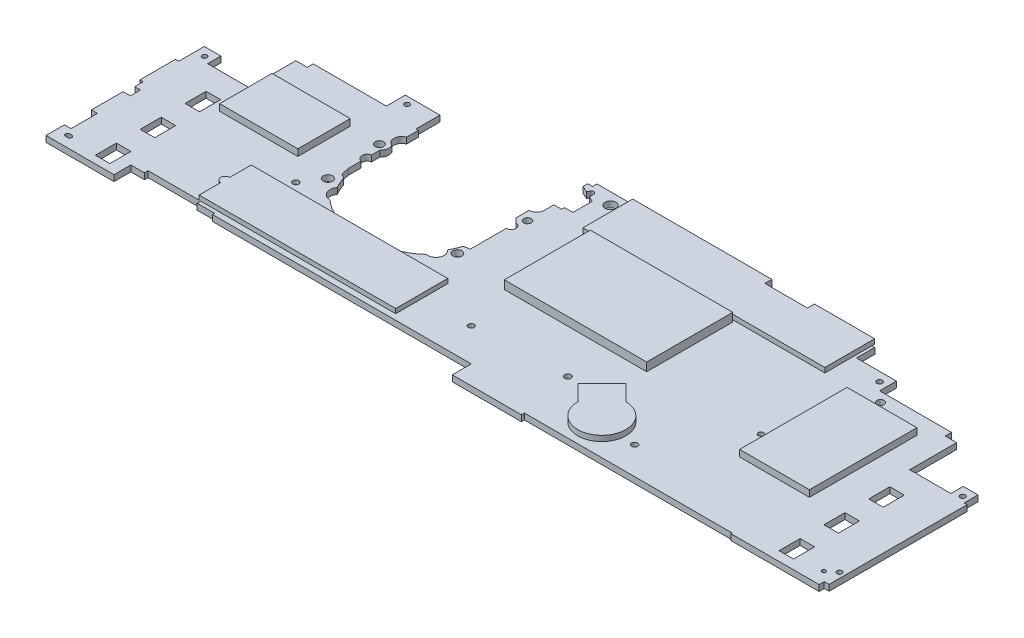
from build123d import *

# Parameters (mm, degrees)
BOSS_EXTRUDE1_DEPTH     = 2.54
SKETCH3_W               = 6.096
SKETCH3_H               = 8.89
SKETCH3_H_2             = 7.366
SKETCH3_R               = 1.016
SKETCH3_R_2             = 1.0795
SKETCH3_R_3             = 1.778
SKETCH3_R_4             = 1.9685
SKETCH3_R_5             = 1.27
SKETCH3_R_6             = 1.905
SKETCH3_R_7             = 2.286
SKETCH3_R_8             = 1.5875
SKETCH3_R_9             = 1.2065
SKETCH3_R_10            = 1.3335
SKETCH3_R_11            = 1.143
SKETCH3_R_12            = 1.524
SKETCH3_R_13            = 0.9525
SKETCH3_H_3             = 7.62
SKETCH3_R_14            = 0.8255
SKETCH3_H_4             = 1.27
SKETCH3_H_5             = 1.524
CUT_EXTRUDE1_DEPTH      = 201.628810234
CUT_EXTRUDE1_DEPTH_BACK = 201.628810234
SKETCH4_R               = 1.905
SKETCH4_W               = 82.931
SKETCH4_H               = 21.971
BOSS_EXTRUDE2_DEPTH     = 1.905
BOSS_EXTRUDE3_DEPTH     = 2
SKETCH6_W               = 60.071
SKETCH6_H               = 36.322
BOSS_EXTRUDE4_DEPTH     = 3.556
SKETCH7_W               = 29.464
SKETCH7_H               = 45.339
BOSS_EXTRUDE5_DEPTH     = 2.794
SKETCH8_W               = 33.02
SKETCH8_H               = 22.1
BOSS_EXTRUDE6_DEPTH     = 2.794
BOSS_EXTRUDE7_DEPTH     = 2.286


with BuildPart() as part:
    # Sketch1 → Boss-Extrude1 (new body)
    with BuildSketch(Plane(origin=(0, 0, 0), x_dir=(1, 0, 0), z_dir=(0, 1, 0))):
        with BuildLine():
            Line((0, 8.001), (0, 0))
            Line((0, 0), (29.21, 0))
            Line((29.21, 0), (29.21, 1.27))
            Line((29.21, 1.27), (116.84, 1.27))
            Line((116.84, 1.27), (116.84, 0.762))
            Line((116.84, 0.762), (154.051, 0.762))
            Line((154.051, 0.762), (154.051, 2.921))
            Line((154.051, 2.921), (156.083, 2.921))
            Line((156.083, 2.921), (156.083, 61.214))
            Line((156.083, 61.214), (154.813, 61.214))
            Line((154.813, 61.214), (154.813, 67.056))
            Line((154.813, 67.056), (148.59, 67.056))
            Line((148.59, 67.056), (148.59, 61.849))
            Line((148.59, 61.849), (131.191, 61.849))
            Line((131.191, 61.849), (131.191, 81.661))
            Line((131.191, 81.661), (126.365, 81.661))
            Line((126.365, 81.661), (126.365, 84.328))
            Line((126.365, 84.328), (96.012, 84.328))
            Line((96.012, 84.328), (96.012, 91.44))
            Line((96.012, 91.44), (79.121, 91.44))
            Line((79.121, 91.44), (79.121, 99.187))
            Line((79.121, 99.187), (42.799, 99.187))
            Line((42.799, 99.187), (42.799, 98.044))
            Line((42.799, 98.044), (35.687, 98.044))
            Line((35.687, 98.044), (35.687, 99.187))
            Line((35.687, 99.187), (34.544, 99.187))
            Line((34.544, 99.187), (34.544, 100.33))
            Line((34.544, 100.33), (-39.243, 100.33))
            Line((-39.243, 100.33), (-39.255297848, 98.431967979))
            Line((-39.255297848, 98.431967979), (-41.287297848, 98.431967979))
            Line((-41.287297848, 98.431967979), (-41.287297848, 96.526967979))
            Line((-41.287297848, 96.526967979), (-38.656255201, 95.245681884))
            ThreePointArc((-38.656255201, 95.245681884), (-38.631310271, 95.294399354), (-38.604432984, 95.342077996))
            Line((-38.604432984, 95.342077996), (-38.04630951, 96.380260766))
            ThreePointArc((-38.04630951, 96.380260766), (-36.937365197, 96.869438836), (-36.192249582, 95.913480995))
            Line((-36.192249582, 95.913480995), (-36.108358632, 94.99611778))
            ThreePointArc((-36.108358632, 94.99611778), (-36.074534662, 94.823441321), (-36.063197248, 94.647848942))
            ThreePointArc((-36.063197248, 94.647848942), (-36.064170573, 94.596301921), (-36.06708916, 94.544828388))
            ThreePointArc((-36.06708916, 94.544828388), (-36.110630044, 94.291080338), (-36.201028424, 94.050016001))
            Line((-36.201028424, 94.050016001), (-33.909, 92.933825752))
            Line((-33.909, 92.933825752), (-33.909, 84.837778338))
            Line((-33.909, 84.837778338), (-37.42811281, 84.837778338))
            Line((-37.42811281, 84.837778338), (-37.42811281, 83.592829399))
            Line((-37.42811281, 83.592829399), (-40.714778008, 83.592829399))
            Line((-40.714778008, 83.592829399), (-40.714778008, 79.537332166))
            ThreePointArc((-40.714778008, 79.537332166), (-41.65506253, 77.267284521), (-43.925110174, 76.327))
            Line((-43.925110174, 76.327), (-43.925110174, 70.782176931))
            Line((-43.925110174, 70.782176931), (-42.14209679, 69.03393907))
            ThreePointArc((-42.14209679, 69.03393907), (-40.073627255, 66.965469535), (-42.14209679, 64.897))
            Line((-42.14209679, 64.897), (-42.14209679, 49.657))
            Line((-42.14209679, 49.657), (-44.657164641, 49.38207208))
            ThreePointArc((-44.657164641, 49.38207208), (-45.543124553, 46.96731208), (-46.71163595, 44.675899429))
            ThreePointArc((-46.71163595, 44.675899429), (-45.665282525, 40.5161147), (-49.482783297, 38.560263904))
            ThreePointArc((-49.482783297, 38.560263904), (-53.685297352, 35.471118381), (-58.472630046, 33.401))
            Line((-58.472630046, 33.401), (-81.840630046, 33.401))
            ThreePointArc((-81.840630046, 33.401), (-86.00575496, 35.359647644), (-89.703732123, 38.1))
            ThreePointArc((-89.703732123, 38.1), (-93.118126886, 40.221112124), (-92.731191221, 44.222048143))
            ThreePointArc((-92.731191221, 44.222048143), (-93.960639772, 46.584635963), (-94.890455929, 49.080393736))
            Line((-94.890455929, 49.080393736), (-96.52, 49.94461297))
            Line((-96.52, 49.94461297), (-97.385045708, 53.369572597))
            Line((-97.385045708, 53.369572597), (-97.385045708, 58.928))
            ThreePointArc((-97.385045708, 58.928), (-99.236932605, 61.135672369), (-97.385045708, 63.343344739))
            Line((-97.385045708, 63.343344739), (-97.385045708, 66.898875353))
            ThreePointArc((-97.385045708, 66.898875353), (-96.253026819, 68.876310747), (-96.649985306, 71.12))
            ThreePointArc((-96.649985306, 71.12), (-98.747141094, 74.213443411), (-96.52, 77.214659345))
            Line((-96.52, 77.214659345), (-96.52, 82.169))
            Line((-96.52, 82.169), (-97.536, 82.169))
            Line((-97.536, 82.169), (-97.536, 92.329))
            Line((-97.536, 92.329), (-112.141, 92.329))
            Line((-112.141, 92.329), (-112.141, 84.328))
            Line((-112.141, 84.328), (-143.002, 84.328))
            Line((-143.002, 84.328), (-143.002, 81.788))
            Line((-143.002, 81.788), (-147.828, 81.788))
            Line((-147.828, 81.788), (-147.828, 62.103))
            Line((-147.828, 62.103), (-165.354, 62.103))
            Line((-165.354, 62.103), (-165.354, 67.691))
            Line((-165.354, 67.691), (-172.339, 67.691))
            Line((-172.339, 67.691), (-172.339, 56.896))
            Line((-172.339, 56.896), (-173.736, 56.896))
            Line((-173.736, 56.896), (-173.736, 41.91))
            Line((-173.736, 41.91), (-172.339, 41.91))
            Line((-172.339, 41.91), (-172.339, 38.354))
            Line((-172.339, 38.354), (-169.926, 38.354))
            Line((-169.926, 38.354), (-169.926, 34.036))
            Line((-169.926, 34.036), (-172.974, 34.036))
            Line((-172.974, 34.036), (-172.974, 20.701))
            Line((-172.974, 20.701), (-170.434, 20.701))
            Line((-170.434, 20.701), (-170.434, 9.525))
            Line((-170.434, 9.525), (-173.228, 9.525))
            Line((-173.228, 9.525), (-173.228, 1.778))
            Line((-173.228, 1.778), (-144.526, 1.778))
            Line((-144.526, 1.778), (-144.526, 8.89))
            Line((-144.526, 8.89), (-138.811, 8.89))
            Line((-138.811, 8.89), (-138.811, 10.414))
            Line((-138.811, 10.414), (-116.586, 10.414))
            Line((-116.586, 10.414), (-116.586, 8.89))
            Line((-116.586, 8.89), (-109.22, 8.89))
            Line((-109.22, 8.89), (-109.22, 8.001))
            Line((-109.22, 8.001), (0, 8.001))
        make_face()
    extrude(amount=BOSS_EXTRUDE1_DEPTH)

    # Sketch3 → Cut-Extrude1 (cut, two sides)
    with BuildSketch(Plane(origin=(0, 1.27, 0), x_dir=(1, 0, 0), z_dir=(0, 1, 0))) as cut_extrude1_sk:
        with BuildLine():
            Line((-168.783, 5.588), (-167.894, 5.588))
            ThreePointArc((-167.894, 5.588), (-167.005, 6.477), (-167.894, 7.366))
            Line((-167.894, 7.366), (-168.783, 7.366))
            ThreePointArc((-168.783, 7.366), (-169.672, 6.477), (-168.783, 5.588))
        make_face()
        with Locations((-152.527, 9.398)):
            Rectangle(SKETCH3_W, SKETCH3_H)
        with Locations((-152.527, 28.321)):
            Rectangle(SKETCH3_W, SKETCH3_H)
        with Locations((-152.527, 46.482)):
            Rectangle(SKETCH3_W, SKETCH3_H_2)
        with Locations(Location((-168.656, 64.135, 0), (0, 0, 270))):
            Circle(SKETCH3_R)
        with Locations(Location((-108.3945, 89.3445, 0), (0, 0, 270))):
            Circle(SKETCH3_R_2)
        with Locations(Location((-99.695, 68.961, 0), (0, 0, 270))):
            Circle(SKETCH3_R_3)
        with Locations(Location((-97.9805, 45.5295, 0), (0, 0, 270))):
            Circle(SKETCH3_R_4)
        with Locations(Location((-103.378, 37.338, 0), (0, 0, 270))):
            Circle(SKETCH3_R_5)
        with Locations(Location((-43.307, 45.466, 0), (0, 0, 270))):
            Circle(SKETCH3_R_6)
        with Locations(Location((-28.587297848, 95.377, 0), (0, 0, 270))):
            Circle(SKETCH3_R_7)
        with Locations(Location((-40.4495, 72.1995, 0), (0, 0, 270))):
            Circle(SKETCH3_R_8)
        with Locations(Location((-13.9065, 21.9075, 0), (0, 0, 270))):
            Circle(SKETCH3_R_9)
        with Locations(Location((24.9555, 23.8125, 0), (0, 0, 270))):
            Circle(SKETCH3_R_10)
        with Locations(Location((92.71, 87.63, 0), (0, 0, 270))):
            Circle(SKETCH3_R_11)
        with Locations(Location((100.457, 80.264, 0), (0, 0, 270))):
            Circle(SKETCH3_R_12)
        with Locations(Location((64.008, 12.954, 0), (0, 0, 270))):
            Circle(SKETCH3_R_5)
        with Locations(Location((86.8045, 43.4975, 0), (0, 0, 270))):
            Circle(SKETCH3_R_11)
        with Locations((86.8045, 43.4975)):
            Circle(SKETCH3_R_13, mode=Mode.SUBTRACT)
        with Locations((86.8045, 43.4975)):
            Circle(SKETCH3_R_13)
        with Locations((136.271, 9.144)):
            Rectangle(SKETCH3_W, SKETCH3_H)
        with Locations((136.271, 28.067)):
            Rectangle(SKETCH3_W, SKETCH3_H)
        with Locations((136.271, 46.355)):
            Rectangle(SKETCH3_W, SKETCH3_H_3)
        with Locations(Location((152.0825, 63.3095, 0), (0, 0, 270))):
            Circle(SKETCH3_R_2)
        with Locations(Location((153.8605, 9.5885, 0), (0, 0, 270))):
            Circle(SKETCH3_R_2)
        with Locations(Location((150.1775, 6.6675, 0), (0, 0, 270))):
            Circle(SKETCH3_R_14)
        with Locations((136.271, 50.8)):
            Rectangle(SKETCH3_W, SKETCH3_H_4)
        with Locations((-152.527, 50.927)):
            Rectangle(SKETCH3_W, SKETCH3_H_5)
    extrude(amount=CUT_EXTRUDE1_DEPTH, mode=Mode.SUBTRACT)
    extrude(cut_extrude1_sk.sketch, amount=-CUT_EXTRUDE1_DEPTH_BACK, mode=Mode.SUBTRACT)

    # Sketch4 → Boss-Extrude2 (add)
    with BuildSketch(Plane(origin=(0, 2.54, 0), x_dir=(1, 0, 0), z_dir=(0, 1, 0))):
        with Locations((-117.221, 21.3995)):
            Circle(SKETCH4_R)
        with Locations((-75.7555, 21.3995)):
            Rectangle(SKETCH4_W, SKETCH4_H)
        with BuildLine():
            ThreePointArc((-115.316, 21.3995), (-115.873961582, 22.746538418), (-117.221, 23.3045))
            Line((-117.221, 23.3045), (-117.221, 19.4945))
            ThreePointArc((-117.221, 19.4945), (-115.873961582, 20.052461582), (-115.316, 21.3995))
        make_face()
        with BuildLine():
            Line((-117.221, 19.4945), (-117.221, 23.3045))
            ThreePointArc((-117.221, 23.3045), (-119.126, 21.3995), (-117.221, 19.4945))
        make_face()
    extrude(amount=BOSS_EXTRUDE2_DEPTH)

    # Sketch5 → Boss-Extrude3 (add)
    with BuildSketch(Plane(origin=(0, 2.54, 0), x_dir=(1, 0, 0), z_dir=(0, 1, 0))):
        Polygon((34.544, 100.33), (-24.187, 100.33), (-24.187, 79.33), (77.921, 79.33), (77.921, 100.33), (52.521480185, 100.33), (52.521480185, 97.381736422), (34.544, 97.381736422), align=None)
    extrude(amount=BOSS_EXTRUDE3_DEPTH)

    # Sketch6 → Boss-Extrude4 (add)
    with BuildSketch(Plane(origin=(0, 2.54, 0), x_dir=(1, 0, 0), z_dir=(0, 1, 0))):
        with Locations((9.8425, 60.325)):
            Rectangle(SKETCH6_W, SKETCH6_H)
    extrude(amount=BOSS_EXTRUDE4_DEPTH)

    # Sketch7 → Boss-Extrude5 (add)
    with BuildSketch(Plane(origin=(0, 2.54, 0), x_dir=(1, 0, 0), z_dir=(0, 1, 0))):
        with Locations((105.41, 53.2765)):
            Rectangle(SKETCH7_W, SKETCH7_H)
    extrude(amount=BOSS_EXTRUDE5_DEPTH)

    # Sketch8 → Boss-Extrude6 (add)
    with BuildSketch(Plane(origin=(0, 2.54, 0), x_dir=(1, 0, 0), z_dir=(0, 1, 0))):
        with Locations((-128.905, 58.292)):
            Rectangle(SKETCH8_W, SKETCH8_H)
    extrude(amount=BOSS_EXTRUDE6_DEPTH)

    # Sketch9 → Boss-Extrude7 (add)
    with BuildSketch(Plane(origin=(0, 2.54, 0), x_dir=(1, 0, 0), z_dir=(0, 1, 0))):
        with BuildLine():
            Line((37.093667043, 26.025332957), (41.583795103, 21.535204897))
            ThreePointArc((41.583795103, 21.535204897), (44.879936327, 23.73761605), (48.768, 24.511))
            Line((48.768, 24.511), (42.173667043, 31.105332957))
            Line((42.173667043, 31.105332957), (37.093667043, 26.025332957))
        make_face()
        with BuildLine():
            ThreePointArc((41.583795103, 21.535204897), (39.38138395, 18.239063673), (38.608, 14.351))
            ThreePointArc((38.608, 14.351), (44.879936327, 4.96438395), (55.952204897, 7.166795103))
            Line((55.952204897, 7.166795103), (41.583795103, 21.535204897))
        make_face()
        with BuildLine():
            Line((41.583795103, 21.535204897), (55.952204897, 7.166795103))
            ThreePointArc((55.952204897, 7.166795103), (58.15461605, 10.462936327), (58.928, 14.351))
            ThreePointArc((58.928, 14.351), (55.952204897, 21.535204897), (48.768, 24.511))
            ThreePointArc((48.768, 24.511), (44.879936327, 23.73761605), (41.583795103, 21.535204897))
        make_face()
        with BuildLine():
            Line((32.013667043, 20.945332957), (38.608, 14.351))
            ThreePointArc((38.608, 14.351), (39.38138395, 18.239063673), (41.583795103, 21.535204897))
            Line((41.583795103, 21.535204897), (37.093667043, 26.025332957))
            Line((37.093667043, 26.025332957), (32.013667043, 20.945332957))
        make_face()
    extrude(amount=BOSS_EXTRUDE7_DEPTH)


solid = part.part
